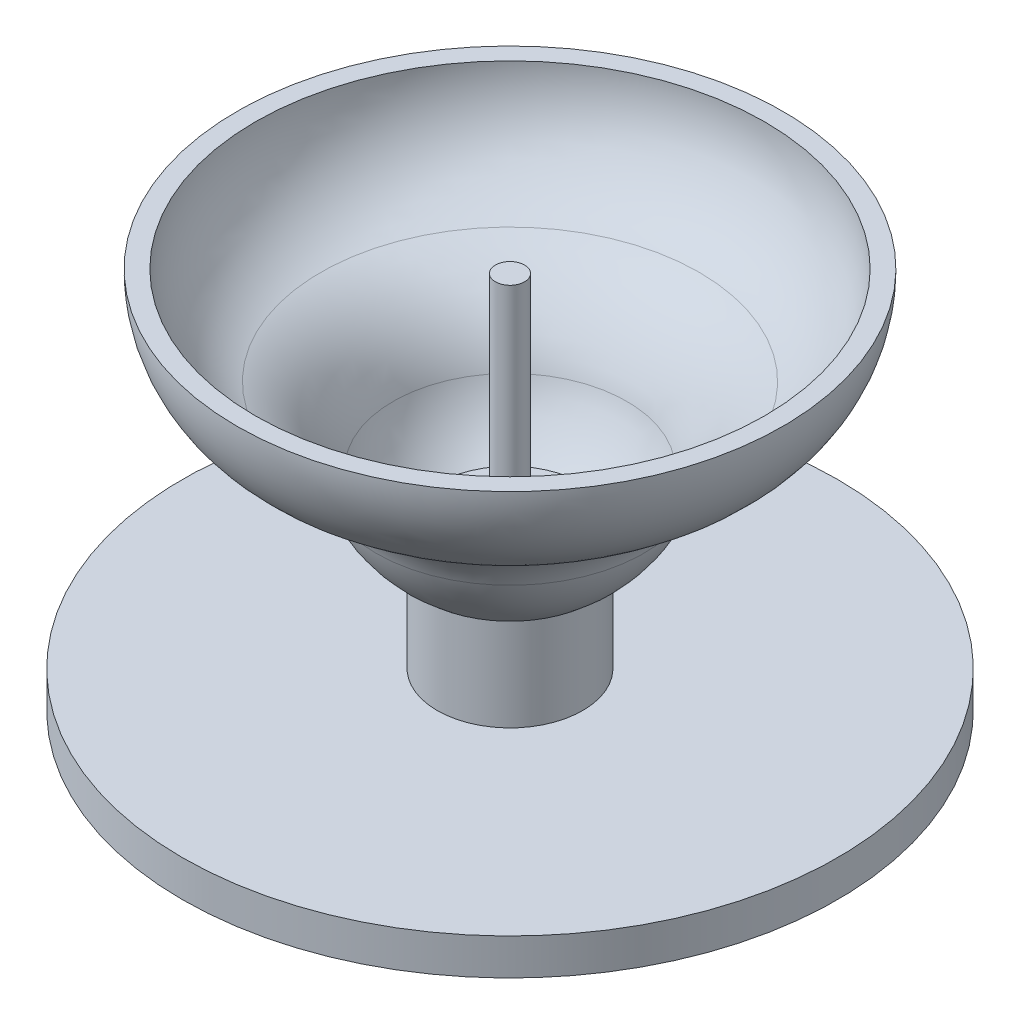
from build123d import *

# Parameters (mm, degrees)
ESQUISSE1_R             = 90
BOSS_EXTRU_1_DEPTH      = 10
ESQUISSE2_R             = 20
BOSS_EXTRU_2_DEPTH      = 93
ESQUISSE4_R             = 75
ESQUISSE4_R_2           = 72
ESQUISSE4_R_3           = 57
ESQUISSE4_R_4           = 54
ESQUISSE4_R_5           = 39
ESQUISSE4_R_6           = 36
ENL_V_MAT_EXTRU_1_DEPTH = 1
ENL_V_MAT_EXTRU_1_TAPER = 30
ESQUISSE5_R             = 20
ENL_V_MAT_EXTRU_2_DEPTH = 59
ESQUISSE6_R             = 4
BOSS_EXTRU_3_DEPTH      = 60


with BuildPart() as part:
    # Esquisse1 → Boss.-Extru.1 (new body)
    with BuildSketch(Plane(origin=(0, 0, 0), x_dir=(1, 0, 0), z_dir=(0, 1, 0))):
        Circle(ESQUISSE1_R)
    extrude(amount=BOSS_EXTRU_1_DEPTH)

    # Esquisse2 → Boss.-Extru.2 (add)
    with BuildSketch(Plane(origin=(0, 10, 0), x_dir=(1, 0, 0), z_dir=(0, 1, 0))):
        Circle(ESQUISSE2_R)
    extrude(amount=BOSS_EXTRU_2_DEPTH)

    # Esquisse4 → Enlèv. mat.-Extru.1 (cut)
    with BuildSketch(Plane.XZ):
        Circle(ESQUISSE4_R)
        Circle(ESQUISSE4_R_2, mode=Mode.SUBTRACT)
        Circle(ESQUISSE4_R_3)
        Circle(ESQUISSE4_R_4, mode=Mode.SUBTRACT)
        Circle(ESQUISSE4_R_5)
        Circle(ESQUISSE4_R_6, mode=Mode.SUBTRACT)
    extrude(amount=-ENL_V_MAT_EXTRU_1_DEPTH, taper=ENL_V_MAT_EXTRU_1_TAPER, mode=Mode.SUBTRACT)

    # Esquisse3 → Révolution2 (revolve)
    with BuildSketch(Plane(origin=(0, 0, 0), x_dir=(0, 0, -1), z_dir=(1, 0, 0))):
        with BuildLine():
            Line((-69.970754953, 105.094254483), (-74.970754953, 105.094254483))
            ThreePointArc((-74.970754953, 105.094254483), (-69.214189796, 86.164390325), (-53.893634743, 73.644071148))
            ThreePointArc((-53.893634743, 73.644071148), (-43.46448587, 66.535394214), (-36.80473888, 55.814004192))
            ThreePointArc((-36.80473888, 55.814004192), (-22.477497728, 37.096821257), (0, 30))
            Line((0, 30), (0, 35))
            ThreePointArc((0, 35), (-19.606403656, 41.190330611), (-32.103598704, 57.516731724))
            ThreePointArc((-32.103598704, 57.516731724), (-39.854721671, 69.995105534), (-51.992962878, 78.26872751))
            ThreePointArc((-51.992962878, 78.26872751), (-65.060675662, 88.947970814), (-69.970754953, 105.094254483))
        make_face()
    revolve(axis=Axis((0, 103, 0), (0, -1, 0)))

    # Esquisse5 → Enlèv. mat.-Extru.2 (cut)
    with BuildSketch(Plane(origin=(0, 103, 0), x_dir=(1, 0, 0), z_dir=(0, 1, 0))):
        Circle(ESQUISSE5_R)
    extrude(amount=-ENL_V_MAT_EXTRU_2_DEPTH, mode=Mode.SUBTRACT)

    # Esquisse6 → Boss.-Extru.3 (add)
    with BuildSketch(Plane(origin=(0, 44, 0), x_dir=(1, 0, 0), z_dir=(0, 1, 0))):
        Circle(ESQUISSE6_R)
    extrude(amount=BOSS_EXTRU_3_DEPTH)


solid = part.part
